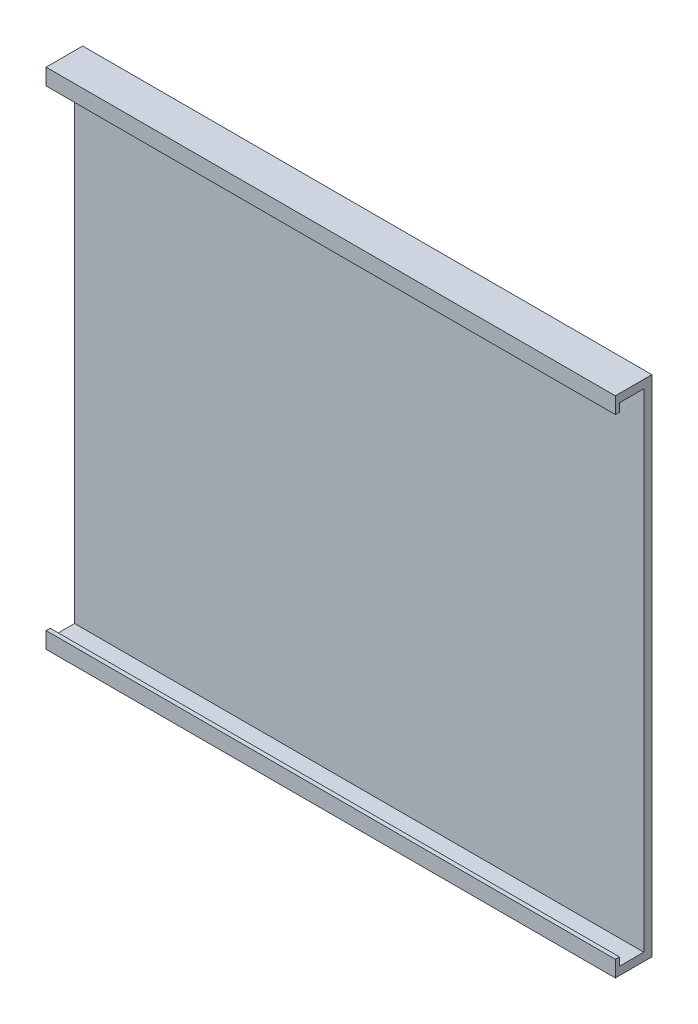
from build123d import *

# Parameters (mm, degrees)
SKETCH_1_W          = 70
SKETCH_1_H          = 62
EXTRUDE_1_DEPTH     = 1
SKETCH_2_W          = 70
SKETCH_2_H          = 2
EXTRUDE_2_DEPTH     = 3.5
SKETCH_6_W          = 3
SKETCH_6_H          = 1
CUT_EXTRUDE_1_DEPTH = 71


with BuildPart() as part:
    # 草图1 → 凸台-拉伸1 (new body)
    with BuildSketch(Plane.XY):
        with Locations((-10.8, 14.6)):
            Rectangle(SKETCH_1_W, SKETCH_1_H)
    extrude(amount=EXTRUDE_1_DEPTH)

    # 草图2 → 凸台-拉伸2 (add)
    with BuildSketch(Plane.XY.offset(1)):
        with Locations((-10.8, 44.6)):
            Rectangle(SKETCH_2_W, SKETCH_2_H)
        with Locations((-10.8, -15.4)):
            Rectangle(SKETCH_2_W, SKETCH_2_H)
    extrude(amount=EXTRUDE_2_DEPTH)

    # 草图6 → 切除-拉伸1 (cut, through all)
    with BuildSketch(Plane.ZY.offset(45.8)):
        with Locations((2.5, 44.1)):
            Rectangle(SKETCH_6_W, SKETCH_6_H)
        with Locations((2.5, -14.9)):
            Rectangle(SKETCH_6_W, SKETCH_6_H)
    extrude(amount=-CUT_EXTRUDE_1_DEPTH, mode=Mode.SUBTRACT)


solid = part.part
